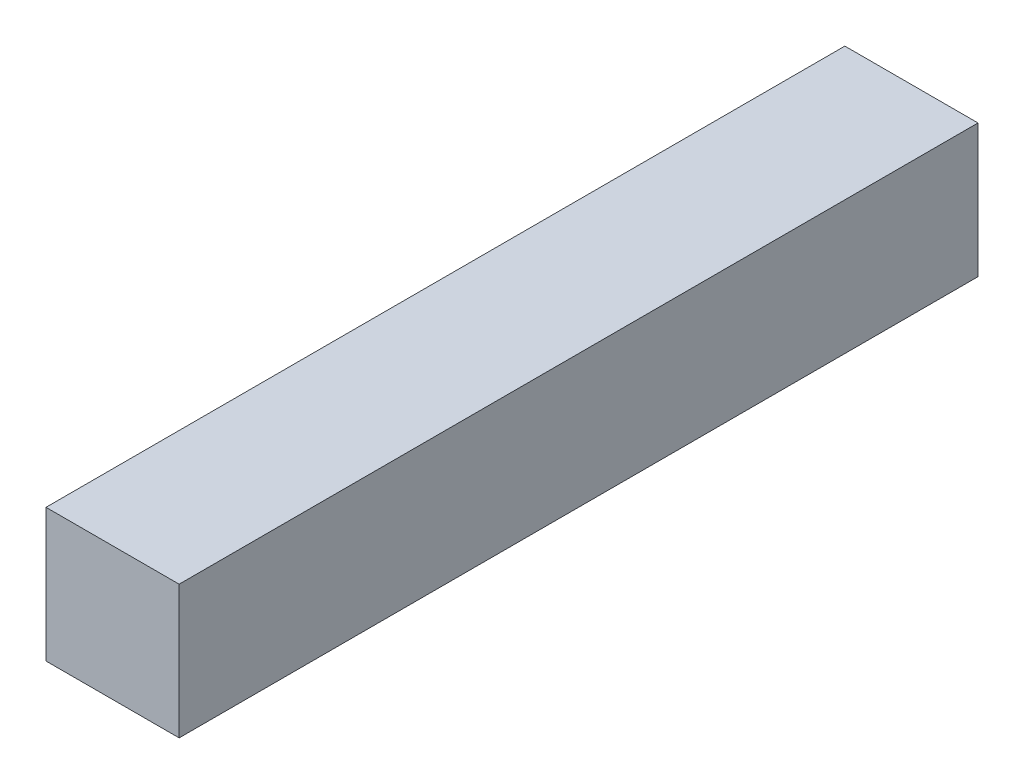
from build123d import *

# Parameters (mm, degrees)
SKETCH1_W           = 15
SKETCH1_H           = 15
BOSS_EXTRUDE1_DEPTH = 90


with BuildPart() as part:
    # Sketch1 → Boss-Extrude1 (new body)
    with BuildSketch(Plane.XY):
        with Locations((7.5, 7.5)):
            Rectangle(SKETCH1_W, SKETCH1_H)
    extrude(amount=BOSS_EXTRUDE1_DEPTH)


solid = part.part
